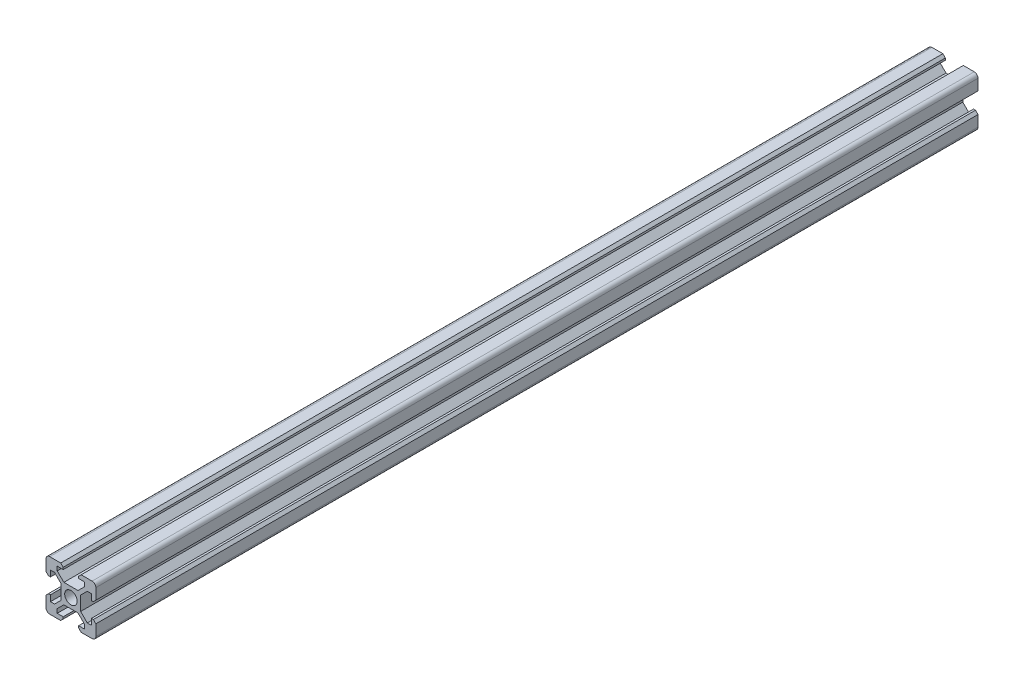
from build123d import *

# Parameters (mm, degrees)
SKETCH1_R           = 2.5
BOSS_EXTRUDE1_DEPTH = 354


with BuildPart() as part:
    # Sketch1 → Boss-Extrude1 (new body)
    with BuildSketch(Plane.XY):
        with BuildLine():
            Line((2.839339828, 3.9), (-2.839339828, 3.9))
            Line((-2.839339828, 3.9), (-5.5, 6.560660172))
            Line((-5.5, 6.560660172), (-5.5, 8.2))
            Line((-5.5, 8.2), (-3.1, 8.2))
            Line((-3.1, 8.2), (-3.1, 9))
            Line((-3.1, 9), (-4.1, 10))
            Line((-4.1, 10), (-8.5, 10))
            ThreePointArc((-8.5, 10), (-9.560660172, 9.560660172), (-10, 8.5))
            Line((-10, 8.5), (-10, 4.1))
            Line((-10, 4.1), (-9, 3.1))
            Line((-9, 3.1), (-8.2, 3.1))
            Line((-8.2, 3.1), (-8.2, 5.5))
            Line((-8.2, 5.5), (-6.560660172, 5.5))
            Line((-6.560660172, 5.5), (-3.9, 2.839339828))
            Line((-3.9, 2.839339828), (-3.9, -2.839339828))
            Line((-3.9, -2.839339828), (-6.560660172, -5.5))
            Line((-6.560660172, -5.5), (-8.2, -5.5))
            Line((-8.2, -5.5), (-8.2, -3.1))
            Line((-8.2, -3.1), (-9, -3.1))
            Line((-9, -3.1), (-10, -4.1))
            Line((-10, -4.1), (-10, -8.5))
            ThreePointArc((-10, -8.5), (-9.560660172, -9.560660172), (-8.5, -10))
            Line((-8.5, -10), (-4.1, -10))
            Line((-4.1, -10), (-3.1, -9))
            Line((-3.1, -9), (-3.1, -8.2))
            Line((-3.1, -8.2), (-5.5, -8.2))
            Line((-5.5, -8.2), (-5.5, -6.560660172))
            Line((-5.5, -6.560660172), (-2.839339828, -3.9))
            Line((-2.839339828, -3.9), (2.839339828, -3.9))
            Line((2.839339828, -3.9), (5.5, -6.560660172))
            Line((5.5, -6.560660172), (5.5, -8.2))
            Line((5.5, -8.2), (3.1, -8.2))
            Line((3.1, -8.2), (3.1, -9))
            Line((3.1, -9), (4.1, -10))
            Line((4.1, -10), (8.5, -10))
            ThreePointArc((8.5, -10), (9.560660172, -9.560660172), (10, -8.5))
            Line((10, -8.5), (10, -4.1))
            Line((10, -4.1), (9, -3.1))
            Line((9, -3.1), (8.2, -3.1))
            Line((8.2, -3.1), (8.2, -5.5))
            Line((8.2, -5.5), (6.560660172, -5.5))
            Line((6.560660172, -5.5), (3.9, -2.839339828))
            Line((3.9, -2.839339828), (3.9, 2.839339828))
            Line((3.9, 2.839339828), (6.560660172, 5.5))
            Line((6.560660172, 5.5), (8.2, 5.5))
            Line((8.2, 5.5), (8.2, 3.1))
            Line((8.2, 3.1), (9, 3.1))
            Line((9, 3.1), (10, 4.1))
            Line((10, 4.1), (10, 8.5))
            ThreePointArc((10, 8.5), (9.560660172, 9.560660172), (8.5, 10))
            Line((8.5, 10), (4.1, 10))
            Line((4.1, 10), (3.1, 9))
            Line((3.1, 9), (3.1, 8.2))
            Line((3.1, 8.2), (5.5, 8.2))
            Line((5.5, 8.2), (5.5, 6.560660172))
            Line((5.5, 6.560660172), (2.839339828, 3.9))
        make_face()
        Circle(SKETCH1_R, mode=Mode.SUBTRACT)
    extrude(amount=BOSS_EXTRUDE1_DEPTH)


solid = part.part
